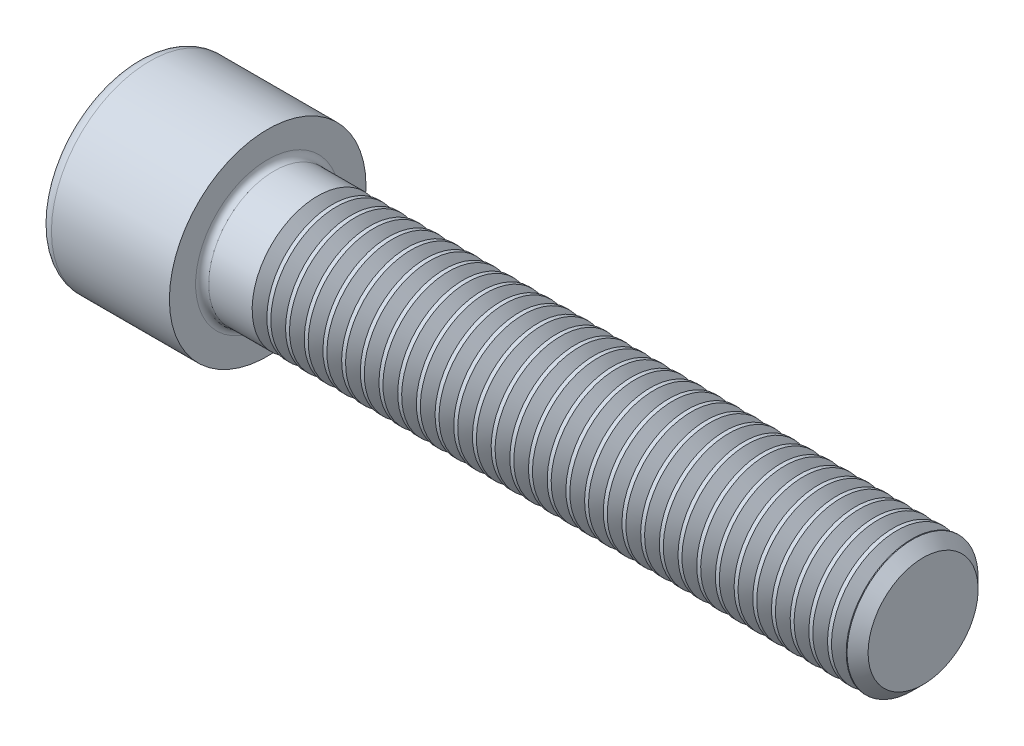
from build123d import *

# Parameters (mm, degrees)
FILLET1_R       = 0.6
FILLET2_R       = 1.2
HEX_2_DEPTH     = 6
THDSCHPAT_COUNT = 32
THDSCHPAT_PITCH = 1.7109375


with BuildPart() as part:
    # BodySke → Base-Revolve (revolve)
    with BuildSketch(Plane.XY, mode=Mode.PRIVATE) as base_revolve_sk:
        Polygon((0, 0), (0, 9), (12, 9), (12, 6), (71.036, 6), (72, 5.036), (72, 0), align=None)
    revolve(base_revolve_sk.sketch.rotate(Axis((-31.75, 0, 0), (1, 0, 0)), 90), axis=Axis((-31.75, 0, 0), (1, 0, 0)))  # turned: the seam where the file's is

    # Fillet1
    fillet1_edges = [part.edges().sort_by_distance(p)[0] for p in [
        (12, 0, -6),
    ]]
    fillet(fillet1_edges, radius=FILLET1_R)

    # Fillet2
    fillet2_edges = [part.edges().sort_by_distance(p)[0] for p in [
        (0, 0, -9),
    ]]
    fillet(fillet2_edges, radius=FILLET2_R)

    # Sketch2 → Hex-PreBroach (revolve, cut)
    with BuildSketch(Plane.XY, mode=Mode.PRIVATE) as hex_prebroach_sk:
        Polygon((0, 5.0125), (6, 5.0125), (8.893968224, 0), (0, 0), align=None)
    revolve(hex_prebroach_sk.sketch.rotate(Axis((0, 0, 0), (1, 0, 0)), 90), axis=Axis((0, 0, 0), (1, 0, 0)), mode=Mode.SUBTRACT)  # turned: the seam where the file's is

    # Sketch3 → Hex 2 (cut)
    with BuildSketch(Plane(origin=(0, 0, 0), x_dir=(0, 0.5, 0.866025404), z_dir=(-1, 0, 0))):
        Polygon((2.893968224, 5.0125), (-2.893968224, 5.0125), (-5.787936449, 0), (-2.893968224, -5.0125), (2.893968224, -5.0125), (5.787936449, 0), align=None)
    extrude(amount=-HEX_2_DEPTH, mode=Mode.SUBTRACT)

    # ThdSchSke → ThreadSchematic (revolve, cut)
    with BuildSketch(Plane.XY, mode=Mode.PRIVATE) as threadschematic_sk:
        Polygon((17.25, -5.036), (16.574999933, -6), (16.574999933, -7.5), (17.925000067, -7.5), (17.925000067, -6), align=None)
    threadschematic = revolve(threadschematic_sk.sketch.rotate(Axis((-3.175, 0, 0), (1, 0, 0)), 270), axis=Axis((-3.175, 0, 0), (1, 0, 0)), mode=Mode.SUBTRACT)  # turned: the seam where the file's is

    # ThdSchPat: ThreadSchematic ×32
    with Locations(*[(i * THDSCHPAT_PITCH, 0, 0) for i in range(1, THDSCHPAT_COUNT)]):
        add(threadschematic, mode=Mode.SUBTRACT)


solid = part.part
